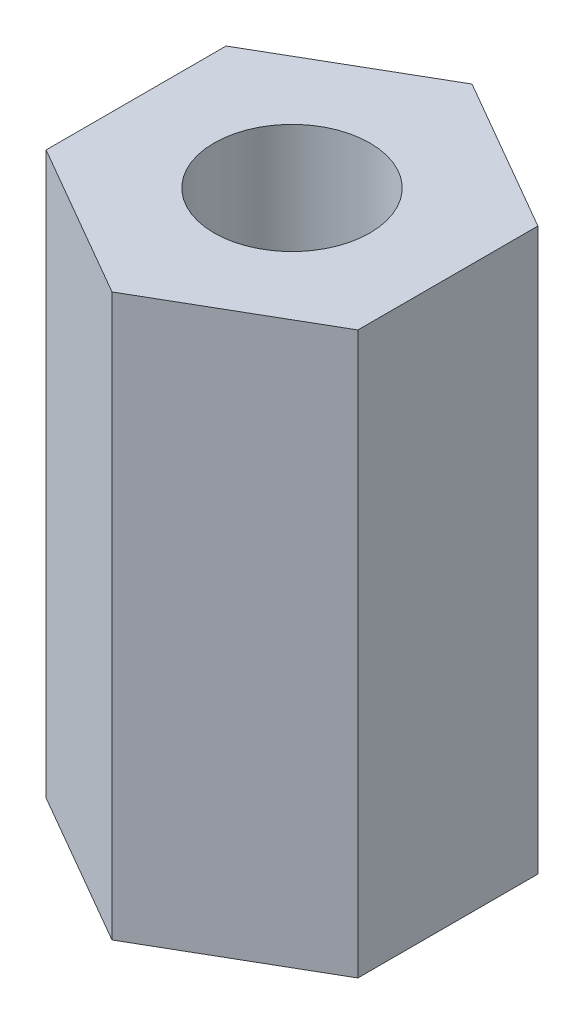
from build123d import *

# Parameters (mm, degrees)
BOSS_EXTRUDE1_DEPTH         = 9
TAP_DRILL_FOR_M3X0_5_TAP1_D = 2.5


with BuildPart() as part:
    # Sketch1 → Boss-Extrude1 (new body)
    with BuildSketch(Plane(origin=(0, 0, 0), x_dir=(1, 0, 0), z_dir=(0, 1, 0))):
        Polygon((2.5, -1.443375673), (2.5, 1.443375673), (0, 2.886751346), (-2.5, 1.443375673), (-2.5, -1.443375673), (0, -2.886751346), align=None)
    extrude(amount=BOSS_EXTRUDE1_DEPTH)

    # Tap Drill for M3x0.5 Tap1 (through all)
    with Locations(Plane(origin=(0, 9, 0), x_dir=(1, 0, 0), z_dir=(0, 1, 0))):
        with Locations((0, 0)):
            Hole(TAP_DRILL_FOR_M3X0_5_TAP1_D / 2)


solid = part.part
